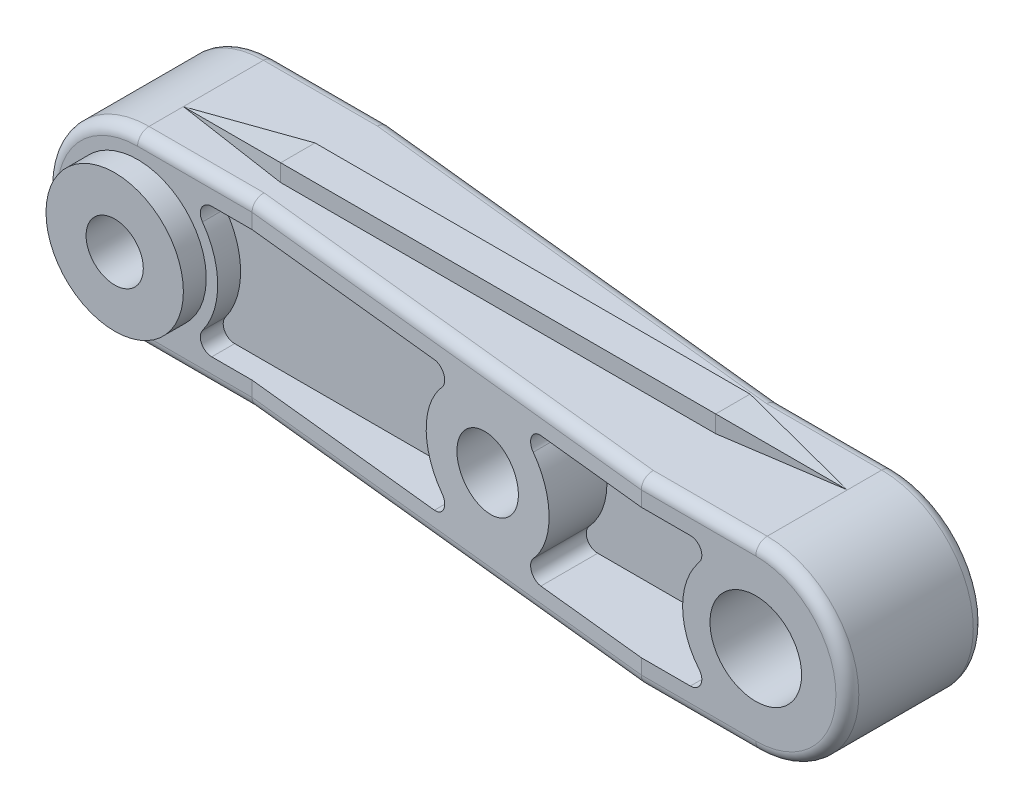
from build123d import *

# Parameters (mm, degrees)
ESQUISSE1_R             = 2
ESQUISSE1_R_2           = 1.5
BASE_EXTRUSION_DEPTH    = 8
ENL_V_MAT_EXTRU_1_DEPTH = 24
ENL_V_MAT_EXTRU_2_DEPTH = 3
BOSS_EXTRU_2_DEPTH      = 0.75
ENL_V_MAT_EXTRU_3_DEPTH = 5.75
CONG_1_R                = 0.5
ESQUISSE9_R             = 3
BOSS_EXTRU_3_DEPTH      = 1
ESQUISSE10_R            = 1.25
ENL_V_MAT_EXTRU_4_DEPTH = 8


with BuildPart() as part:
    # Esquisse1 → Base-Extrusion (new body)
    with BuildSketch(Plane.XY):
        with BuildLine():
            Line((0, 4), (29, 4))
            ThreePointArc((29, 4), (33, 0), (29, -4))
            Line((29, -4), (0, -4))
            ThreePointArc((0, -4), (-4, 0), (0, 4))
        make_face()
        with Locations((29, 0)):
            Circle(ESQUISSE1_R, mode=Mode.SUBTRACT)
        with Locations((16.5, 0)):
            Circle(ESQUISSE1_R_2, mode=Mode.SUBTRACT)
    extrude(amount=BASE_EXTRUSION_DEPTH)

    # Esquisse2 → Enlèv. mat.-Extru.1 (cut, symmetric)
    with BuildSketch(Plane(origin=(0, 0, 0), x_dir=(1, 0, 0), z_dir=(0, 1, 0))):
        Polygon((-4, 0), (5, 0), (24, -2), (32, -2), (34, -2), (34, 2), (-5, 2), (-5, 0), align=None)
        Polygon((30, -8), (24, -8), (5, -6), (-5, -6), (-5, -9), (35, -9), (35, -8), align=None)
    extrude(amount=ENL_V_MAT_EXTRU_1_DEPTH, both=True, mode=Mode.SUBTRACT)

    # Esquisse3 → Enlèv. mat.-Extru.2 (cut)
    with BuildSketch(Plane.XY.offset(8)):
        with BuildLine():
            Line((26.143442915, 2.846006946), (19.097354695, 2.846006946))
            ThreePointArc((19.097354695, 2.846006946), (18.640423669, 2.549019353), (18.726304024, 2.010863096))
            ThreePointArc((18.726304024, 2.010863096), (19.5, 0), (18.726304024, -2.010863096))
            ThreePointArc((18.726304024, -2.010863096), (18.640423669, -2.549019353), (19.097354695, -2.846006946))
            Line((19.097354695, -2.846006946), (26.143442915, -2.846006946))
            ThreePointArc((26.143442915, -2.846006946), (26.595475356, -2.559704564), (26.529835939, -2.028673634))
            ThreePointArc((26.529835939, -2.028673634), (25.80356023, 0), (26.529835939, 2.028673634))
            ThreePointArc((26.529835939, 2.028673634), (26.595475356, 2.559704564), (26.143442915, 2.846006946))
        make_face()
        with BuildLine():
            Line((13.902645305, 2.846006946), (3.239791878, 2.846006946))
            ThreePointArc((3.239791878, 2.846006946), (2.794468717, 2.573355319), (2.834817893, 2.052756078))
            ThreePointArc((2.834817893, 2.052756078), (3.5, 0), (2.834817893, -2.052756078))
            ThreePointArc((2.834817893, -2.052756078), (2.794468717, -2.573355319), (3.239791878, -2.846006946))
            Line((3.239791878, -2.846006946), (13.902645305, -2.846006946))
            ThreePointArc((13.902645305, -2.846006946), (14.359576331, -2.549019353), (14.273695976, -2.010863096))
            ThreePointArc((14.273695976, -2.010863096), (13.5, 0), (14.273695976, 2.010863096))
            ThreePointArc((14.273695976, 2.010863096), (14.359576331, 2.549019353), (13.902645305, 2.846006946))
        make_face()
    enl_v_mat_extru_2 = extrude(amount=-ENL_V_MAT_EXTRU_2_DEPTH, mode=Mode.SUBTRACT)

    # Symétrie1: Enlèv. mat.-Extru.2 across plane
    add(enl_v_mat_extru_2.mirror(Plane(origin=(0, 0, 4), x_dir=(1, 0, 0), z_dir=(0, 0, -1))), mode=Mode.SUBTRACT)

    # Esquisse7 → Boss.-Extru.2 (add)
    with BuildSketch(Plane.XZ.offset(4)):
        Polygon((5, 3.25), (24, 3.25), (29, 4), (24, 4.75), (5, 4.75), (0, 4), align=None)
    boss_extru_2 = extrude(amount=BOSS_EXTRU_2_DEPTH)

    # Symétrie2: Boss.-Extru.2 across plane
    add(boss_extru_2.mirror(Plane.ZX))

    # Esquisse8 → Enlèv. mat.-Extru.3 (cut, through all)
    with BuildSketch(Plane.XY.offset(4.75)):
        Polygon((0, 4), (5, 4.75), (5, 7), (0, 7), align=None)
        Polygon((24, 4.75), (29, 4), (29, 7), (24, 7), align=None)
        Polygon((29, -7), (24, -7), (24, -4.75), (29, -4), align=None)
        Polygon((5, -4.75), (5, -7), (0, -7), (0, -4), align=None)
    extrude(amount=-ENL_V_MAT_EXTRU_3_DEPTH, mode=Mode.SUBTRACT)

    # Congé1
    cong_1_edges = [part.edges().sort_by_distance(p)[0] for p in [
        (26.5, -4, 2),
        (14.5, -4, 1),
        (2.5, -4, 0),
        (33, 0, 2),
        (33, 0, 8),
        (26.5, -4, 8),
        (14.5, -4, 7),
        (2.5, -4, 6),
        (2.5, 4, 6),
        (-4, 0, 6),
        (14.5, 4, 7),
        (26.5, 4, 8),
        (2.5, 4, 0),
        (14.5, 4, 1),
        (26.5, 4, 2),
        (-4, 0, 0),
    ]]
    fillet(cong_1_edges, radius=CONG_1_R)

    # Esquisse9 → Boss.-Extru.3 (add)
    with BuildSketch(Plane.XY.offset(6)):
        Circle(ESQUISSE9_R)
    extrude(amount=BOSS_EXTRU_3_DEPTH)

    # Esquisse10 → Enlèv. mat.-Extru.4 (cut, through all)
    with BuildSketch(Plane.XY.offset(7)):
        Circle(ESQUISSE10_R)
    extrude(amount=-ENL_V_MAT_EXTRU_4_DEPTH, mode=Mode.SUBTRACT)


solid = part.part
